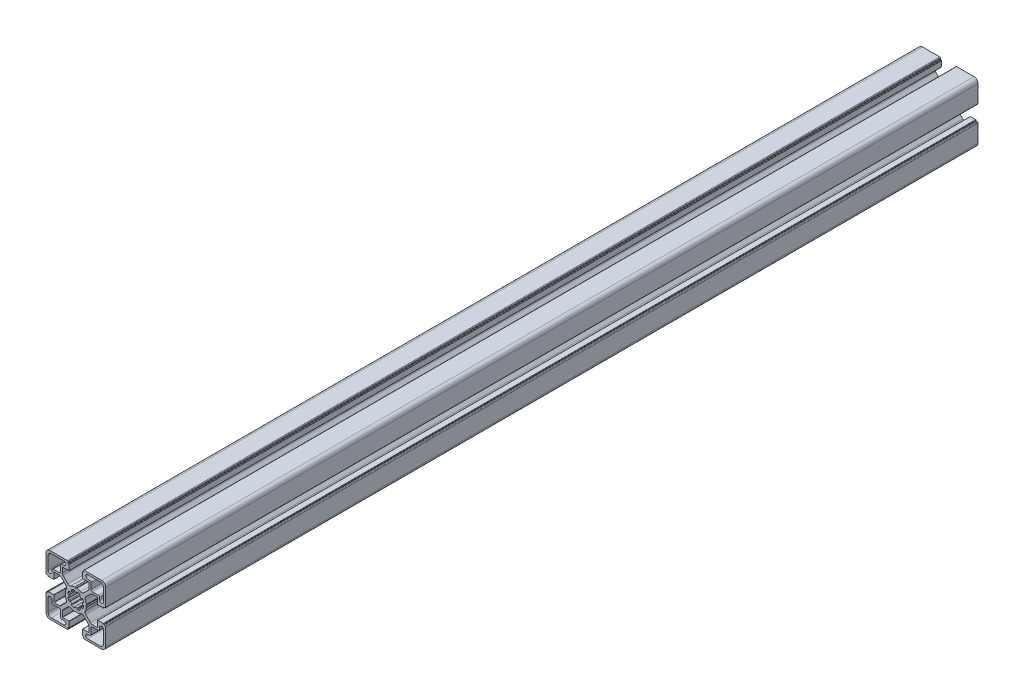
from build123d import *

# Parameters (mm, degrees)
BASE_EXTRUDE_DEPTH = 659


with BuildPart() as part:
    # Sketch1 → Base-Extrude (new body)
    with BuildSketch(Plane.XY):
        with BuildLine():
            Line((7.973976585, 0.792591518), (7.540060475, 0.046829556))
            ThreePointArc((7.540060475, 0.046829556), (7.534295984, 0.023675638), (7.531329941, 0))
            ThreePointArc((7.531329941, 0), (7.534295984, -0.023675638), (7.540060475, -0.046829556))
            Line((7.540060475, -0.046829556), (7.973976585, -0.792591518))
            ThreePointArc((7.973976585, -0.792591518), (7.996666421, -0.851255641), (8.000014047, -0.914065683))
            ThreePointArc((8.000014047, -0.914065683), (7.719730741, -2.298395946), (7.20036345, -3.611859543))
            ThreePointArc((7.20036345, -3.611859543), (7.018857217, -4.793954471), (7.563483933, -5.85869607))
            Line((7.563483933, -5.85869607), (11.129779889, -9.424988026))
            ThreePointArc((11.129779889, -9.424988026), (11.760624613, -9.84650461), (12.504756513, -9.99452154))
            Line((12.504756513, -9.99452154), (16.316902451, -9.99452154))
            ThreePointArc((16.316902451, -9.99452154), (16.458324055, -9.935942793), (16.516902802, -9.794521189))
            Line((16.516902802, -9.794521189), (16.516902802, -5.200014226))
            ThreePointArc((16.516902802, -5.200014226), (16.575481548, -5.058592621), (16.716903152, -5.000013875))
            Line((16.716903152, -5.000013875), (20.719599904, -5.000013875))
            ThreePointArc((20.719599904, -5.000013875), (20.931731427, -5.087881629), (21.01959918, -5.300013151))
            Line((21.01959918, -5.300013151), (21.01959918, -5.500004099))
            ThreePointArc((21.01959918, -5.500004099), (21.10746708, -5.712135974), (21.319598956, -5.800003874))
            Line((21.319598956, -5.800003874), (21.999979514, -5.800003874))
            ThreePointArc((21.999979514, -5.800003874), (22.35353264, -5.946450374), (22.49997914, -6.300003501))
            Line((22.49997914, -6.300003501), (22.49997914, -19.500016116))
            ThreePointArc((22.49997914, -19.500016116), (21.62130014, -21.621334875), (19.499981381, -22.500013875))
            Line((19.499981381, -22.500013875), (6.375709012, -22.500013875))
            ThreePointArc((6.375709012, -22.500013875), (6.022155886, -22.353567375), (5.875709386, -22.000014249))
            Line((5.875709386, -22.000014249), (5.875709386, -21.30001315))
            ThreePointArc((5.875709386, -21.30001315), (5.787841632, -21.087881628), (5.57571011, -21.000013874))
            Line((5.57571011, -21.000013874), (5.299998776, -21.000013874))
            ThreePointArc((5.299998776, -21.000013874), (5.087867607, -20.912146267), (5, -20.700015099))
            Line((5, -20.700015099), (5, -16.666812433))
            ThreePointArc((5, -16.666812433), (5.058578893, -16.525390475), (5.200000851, -16.466811582))
            Line((5.200000851, -16.466811582), (9.905385218, -16.466811582))
            ThreePointArc((9.905385218, -16.466811582), (10.046806822, -16.408232835), (10.105385569, -16.266811231))
            Line((10.105385569, -16.266811231), (10.105385569, -12.471582956))
            ThreePointArc((10.105385569, -12.471582956), (9.953144588, -11.706215861), (9.519598955, -11.057368968))
            Line((9.519598955, -11.057368968), (5.944897989, -7.482668002))
            ThreePointArc((5.944897989, -7.482668002), (4.854601835, -6.967833724), (3.666499237, -7.173289937))
            ThreePointArc((3.666499237, -7.173289937), (2.309136684, -7.713848333), (0.876396038, -8.000013875))
            ThreePointArc((0.876396038, -8.000013875), (0.81356491, -7.997088573), (0.754749577, -7.974793627))
            Line((0.754749577, -7.974793627), (0.11262846, -7.606936933))
            ThreePointArc((0.11262846, -7.606936933), (0.062963903, -7.559088739), (0, -7.530953975))
            ThreePointArc((0, -7.530953975), (-0.062963903, -7.559088739), (-0.11262846, -7.606936933))
            Line((-0.11262846, -7.606936933), (-0.754749577, -7.974793627))
            ThreePointArc((-0.754749577, -7.974793627), (-0.81356491, -7.997088573), (-0.876396038, -8.000013875))
            ThreePointArc((-0.876396038, -8.000013875), (-2.309136684, -7.713848333), (-3.666499237, -7.173289937))
            ThreePointArc((-3.666499237, -7.173289937), (-4.854601835, -6.967833724), (-5.944897989, -7.482668002))
            Line((-5.944897989, -7.482668002), (-9.519598955, -11.057368968))
            ThreePointArc((-9.519598955, -11.057368968), (-9.953144588, -11.706215861), (-10.105385569, -12.471582956))
            Line((-10.105385569, -12.471582956), (-10.105385569, -16.266811231))
            ThreePointArc((-10.105385569, -16.266811231), (-10.046806822, -16.408232835), (-9.905385218, -16.466811582))
            Line((-9.905385218, -16.466811582), (-5.200000851, -16.466811582))
            ThreePointArc((-5.200000851, -16.466811582), (-5.058578893, -16.525390475), (-5, -16.666812433))
            Line((-5, -16.666812433), (-5, -20.700015099))
            ThreePointArc((-5, -20.700015099), (-5.087867607, -20.912146267), (-5.299998776, -21.000013874))
            Line((-5.299998776, -21.000013874), (-5.57571011, -21.000013874))
            ThreePointArc((-5.57571011, -21.000013874), (-5.787841632, -21.087881628), (-5.875709386, -21.30001315))
            Line((-5.875709386, -21.30001315), (-5.875709386, -22.000014249))
            ThreePointArc((-5.875709386, -22.000014249), (-6.022155886, -22.353567375), (-6.375709012, -22.500013875))
            Line((-6.375709012, -22.500013875), (-19.499981381, -22.500013875))
            ThreePointArc((-19.499981381, -22.500013875), (-21.62130014, -21.621334875), (-22.49997914, -19.500016116))
            Line((-22.49997914, -19.500016116), (-22.49997914, -6.300003501))
            ThreePointArc((-22.49997914, -6.300003501), (-22.35353264, -5.946450374), (-21.999979514, -5.800003874))
            Line((-21.999979514, -5.800003874), (-21.319598956, -5.800003874))
            ThreePointArc((-21.319598956, -5.800003874), (-21.10746708, -5.712135974), (-21.01959918, -5.500004099))
            Line((-21.01959918, -5.500004099), (-21.01959918, -5.300013151))
            ThreePointArc((-21.01959918, -5.300013151), (-20.931731427, -5.087881629), (-20.719599904, -5.000013875))
            Line((-20.719599904, -5.000013875), (-16.716903152, -5.000013875))
            ThreePointArc((-16.716903152, -5.000013875), (-16.575481548, -5.058592621), (-16.516902802, -5.200014226))
            Line((-16.516902802, -5.200014226), (-16.516902802, -9.794521189))
            ThreePointArc((-16.516902802, -9.794521189), (-16.458324055, -9.935942793), (-16.316902451, -9.99452154))
            Line((-16.316902451, -9.99452154), (-12.504756513, -9.99452154))
            ThreePointArc((-12.504756513, -9.99452154), (-11.760624613, -9.84650461), (-11.129779889, -9.424988026))
            Line((-11.129779889, -9.424988026), (-7.563483933, -5.85869607))
            ThreePointArc((-7.563483933, -5.85869607), (-7.018857217, -4.793954471), (-7.20036345, -3.611859543))
            ThreePointArc((-7.20036345, -3.611859543), (-7.719730741, -2.298395946), (-8.000014047, -0.914065683))
            ThreePointArc((-8.000014047, -0.914065683), (-7.996666421, -0.851255641), (-7.973976585, -0.792591518))
            Line((-7.973976585, -0.792591518), (-7.540060475, -0.046829556))
            ThreePointArc((-7.540060475, -0.046829556), (-7.534295984, -0.023675638), (-7.531329941, 0))
            ThreePointArc((-7.531329941, 0), (-7.534295984, 0.023675638), (-7.540060475, 0.046829556))
            Line((-7.540060475, 0.046829556), (-7.973976585, 0.792591518))
            ThreePointArc((-7.973976585, 0.792591518), (-7.996666421, 0.851255641), (-8.000014047, 0.914065683))
            ThreePointArc((-8.000014047, 0.914065683), (-7.719730741, 2.298395946), (-7.20036345, 3.611859543))
            ThreePointArc((-7.20036345, 3.611859543), (-7.018857217, 4.793954471), (-7.563483933, 5.85869607))
            Line((-7.563483933, 5.85869607), (-11.129779889, 9.424988026))
            ThreePointArc((-11.129779889, 9.424988026), (-11.760624613, 9.84650461), (-12.504756513, 9.99452154))
            Line((-12.504756513, 9.99452154), (-16.316902451, 9.99452154))
            ThreePointArc((-16.316902451, 9.99452154), (-16.458324055, 9.935942793), (-16.516902802, 9.794521189))
            Line((-16.516902802, 9.794521189), (-16.516902802, 5.200014226))
            ThreePointArc((-16.516902802, 5.200014226), (-16.575481548, 5.058592621), (-16.716903152, 5.000013875))
            Line((-16.716903152, 5.000013875), (-20.719599904, 5.000013875))
            ThreePointArc((-20.719599904, 5.000013875), (-20.931731427, 5.087881629), (-21.01959918, 5.300013151))
            Line((-21.01959918, 5.300013151), (-21.01959918, 5.500004099))
            ThreePointArc((-21.01959918, 5.500004099), (-21.10746708, 5.712135974), (-21.319598956, 5.800003874))
            Line((-21.319598956, 5.800003874), (-21.999979514, 5.800003874))
            ThreePointArc((-21.999979514, 5.800003874), (-22.35353264, 5.946450374), (-22.49997914, 6.300003501))
            Line((-22.49997914, 6.300003501), (-22.49997914, 19.500016116))
            ThreePointArc((-22.49997914, 19.500016116), (-21.62130014, 21.621334875), (-19.499981381, 22.500013875))
            Line((-19.499981381, 22.500013875), (-6.375709012, 22.500013875))
            ThreePointArc((-6.375709012, 22.500013875), (-6.022155886, 22.353567375), (-5.875709386, 22.000014249))
            Line((-5.875709386, 22.000014249), (-5.875709386, 21.30001315))
            ThreePointArc((-5.875709386, 21.30001315), (-5.787841632, 21.087881628), (-5.57571011, 21.000013874))
            Line((-5.57571011, 21.000013874), (-5.299998776, 21.000013874))
            ThreePointArc((-5.299998776, 21.000013874), (-5.087867607, 20.912146267), (-5, 20.700015099))
            Line((-5, 20.700015099), (-5, 16.666812433))
            ThreePointArc((-5, 16.666812433), (-5.058578893, 16.525390475), (-5.200000851, 16.466811582))
            Line((-5.200000851, 16.466811582), (-9.905385218, 16.466811582))
            ThreePointArc((-9.905385218, 16.466811582), (-10.046806822, 16.408232835), (-10.105385569, 16.266811231))
            Line((-10.105385569, 16.266811231), (-10.105385569, 12.471582956))
            ThreePointArc((-10.105385569, 12.471582956), (-9.953144588, 11.706215861), (-9.519598955, 11.057368968))
            Line((-9.519598955, 11.057368968), (-5.944897989, 7.482668002))
            ThreePointArc((-5.944897989, 7.482668002), (-4.854601835, 6.967833724), (-3.666499237, 7.173289937))
            ThreePointArc((-3.666499237, 7.173289937), (-2.309136684, 7.713848333), (-0.876396038, 8.000013875))
            ThreePointArc((-0.876396038, 8.000013875), (-0.81356491, 7.997088573), (-0.754749577, 7.974793627))
            Line((-0.754749577, 7.974793627), (-0.11262846, 7.606936933))
            ThreePointArc((-0.11262846, 7.606936933), (-0.062963903, 7.559088739), (0, 7.530953975))
            ThreePointArc((0, 7.530953975), (0.062963903, 7.559088739), (0.11262846, 7.606936933))
            Line((0.11262846, 7.606936933), (0.754749577, 7.974793627))
            ThreePointArc((0.754749577, 7.974793627), (0.81356491, 7.997088573), (0.876396038, 8.000013875))
            ThreePointArc((0.876396038, 8.000013875), (2.309136684, 7.713848333), (3.666499237, 7.173289937))
            ThreePointArc((3.666499237, 7.173289937), (4.854601835, 6.967833724), (5.944897989, 7.482668002))
            Line((5.944897989, 7.482668002), (9.519598955, 11.057368968))
            ThreePointArc((9.519598955, 11.057368968), (9.953144588, 11.706215861), (10.105385569, 12.471582956))
            Line((10.105385569, 12.471582956), (10.105385569, 16.266811231))
            ThreePointArc((10.105385569, 16.266811231), (10.046806822, 16.408232835), (9.905385218, 16.466811582))
            Line((9.905385218, 16.466811582), (5.200000851, 16.466811582))
            ThreePointArc((5.200000851, 16.466811582), (5.058578893, 16.525390475), (5, 16.666812433))
            Line((5, 16.666812433), (5, 20.700015099))
            ThreePointArc((5, 20.700015099), (5.087867607, 20.912146267), (5.299998776, 21.000013874))
            Line((5.299998776, 21.000013874), (5.57571011, 21.000013874))
            ThreePointArc((5.57571011, 21.000013874), (5.787841632, 21.087881628), (5.875709386, 21.30001315))
            Line((5.875709386, 21.30001315), (5.875709386, 22.000014249))
            ThreePointArc((5.875709386, 22.000014249), (6.022155886, 22.353567375), (6.375709012, 22.500013875))
            Line((6.375709012, 22.500013875), (19.499981381, 22.500013875))
            ThreePointArc((19.499981381, 22.500013875), (21.62130014, 21.621334875), (22.49997914, 19.500016116))
            Line((22.49997914, 19.500016116), (22.49997914, 6.300003501))
            ThreePointArc((22.49997914, 6.300003501), (22.35353264, 5.946450374), (21.999979514, 5.800003874))
            Line((21.999979514, 5.800003874), (21.319598956, 5.800003874))
            ThreePointArc((21.319598956, 5.800003874), (21.10746708, 5.712135974), (21.01959918, 5.500004099))
            Line((21.01959918, 5.500004099), (21.01959918, 5.300013151))
            ThreePointArc((21.01959918, 5.300013151), (20.931731427, 5.087881629), (20.719599904, 5.000013875))
            Line((20.719599904, 5.000013875), (16.716903152, 5.000013875))
            ThreePointArc((16.716903152, 5.000013875), (16.575481548, 5.058592621), (16.516902802, 5.200014226))
            Line((16.516902802, 5.200014226), (16.516902802, 9.794521189))
            ThreePointArc((16.516902802, 9.794521189), (16.458324055, 9.935942793), (16.316902451, 9.99452154))
            Line((16.316902451, 9.99452154), (12.504756513, 9.99452154))
            ThreePointArc((12.504756513, 9.99452154), (11.760624613, 9.84650461), (11.129779889, 9.424988026))
            Line((11.129779889, 9.424988026), (7.563483933, 5.85869607))
            ThreePointArc((7.563483933, 5.85869607), (7.018857217, 4.793954471), (7.20036345, 3.611859543))
            ThreePointArc((7.20036345, 3.611859543), (7.719730741, 2.298395946), (8.000014047, 0.914065683))
            ThreePointArc((8.000014047, 0.914065683), (7.996666421, 0.851255641), (7.973976585, 0.792591518))
        make_face()
        with BuildLine():
            Line((10.549978885, 18.000013874), (8.999979138, 18.000013874))
            ThreePointArc((8.999979138, 18.000013874), (7.499979138, 19.500013874), (8.999979138, 21.000013874))
            Line((8.999979138, 21.000013874), (18.499981006, 21.000013874))
            ThreePointArc((18.499981006, 21.000013874), (20.267746638, 20.267781374), (20.999979138, 18.500015742))
            Line((20.999979138, 18.500015742), (20.999979138, 9.000204874))
            ThreePointArc((20.999979138, 9.000204874), (19.499979138, 7.500204874), (17.999979138, 9.000204874))
            Line((17.999979138, 9.000204874), (17.999979138, 10.550013621))
            ThreePointArc((17.999979138, 10.550013621), (17.707086138, 11.257119874), (16.999979885, 11.550012874))
            Line((16.999979885, 11.550012874), (12.549977391, 11.550012874))
            ThreePointArc((12.549977391, 11.550012874), (11.842871138, 11.842905874), (11.549978138, 12.550012127))
            Line((11.549978138, 12.550012127), (11.549978138, 17.000014621))
            ThreePointArc((11.549978138, 17.000014621), (11.257085138, 17.707120874), (10.549978885, 18.000013874))
        make_face(mode=Mode.SUBTRACT)
        with BuildLine():
            Line((-0.867388737, 4.924188946), (-0.96752168, 5.481112935))
            ThreePointArc((-0.96752168, 5.481112935), (-1.187855719, 5.829589164), (-1.595071417, 5.894072848))
            ThreePointArc((-1.595071417, 5.894072848), (-2.338895973, 5.643477696), (-3.04438497, 5.299445466))
            ThreePointArc((-3.04438497, 5.299445466), (-3.284615367, 4.964275075), (-3.191311906, 4.562598216))
            Line((-3.191311906, 4.562598216), (-2.864000421, 4.09847552))
            ThreePointArc((-2.864000421, 4.09847552), (-3.53013295, 3.540926624), (-4.08971289, 2.876499344))
            Line((-4.08971289, 2.876499344), (-4.566777651, 3.208162503))
            ThreePointArc((-4.566777651, 3.208162503), (-4.968960845, 3.298770682), (-5.302497889, 3.056460542))
            ThreePointArc((-5.302497889, 3.056460542), (-5.651259984, 2.353310881), (-5.906847665, 1.611199444))
            ThreePointArc((-5.906847665, 1.611199444), (-5.839752063, 1.204293023), (-5.489730697, 0.98621116))
            Line((-5.489730697, 0.98621116), (-4.920545766, 0.887822825))
            ThreePointArc((-4.920545766, 0.887822825), (-4.980096828, 0.445685524), (-5, 0))
            ThreePointArc((-5, 0), (-4.980096828, -0.445685524), (-4.920545766, -0.887822825))
            Line((-4.920545766, -0.887822825), (-5.489730697, -0.98621116))
            ThreePointArc((-5.489730697, -0.98621116), (-5.839752063, -1.204293023), (-5.906847665, -1.611199444))
            ThreePointArc((-5.906847665, -1.611199444), (-5.651259984, -2.353310881), (-5.302497889, -3.056460542))
            ThreePointArc((-5.302497889, -3.056460542), (-4.968960845, -3.298770682), (-4.566777651, -3.208162503))
            Line((-4.566777651, -3.208162503), (-4.08971289, -2.876499344))
            ThreePointArc((-4.08971289, -2.876499344), (-3.53013295, -3.540926624), (-2.864000421, -4.09847552))
            Line((-2.864000421, -4.09847552), (-3.191311906, -4.562598216))
            ThreePointArc((-3.191311906, -4.562598216), (-3.284615367, -4.964275075), (-3.04438497, -5.299445466))
            ThreePointArc((-3.04438497, -5.299445466), (-2.338895973, -5.643477696), (-1.595071417, -5.894072848))
            ThreePointArc((-1.595071417, -5.894072848), (-1.187855719, -5.829589164), (-0.96752168, -5.481112935))
            Line((-0.96752168, -5.481112935), (-0.867388737, -4.924188946))
            ThreePointArc((-0.867388737, -4.924188946), (0, -5), (0.867388737, -4.924188946))
            Line((0.867388737, -4.924188946), (0.96752168, -5.481112935))
            ThreePointArc((0.96752168, -5.481112935), (1.187855719, -5.829589164), (1.595071417, -5.894072848))
            ThreePointArc((1.595071417, -5.894072848), (2.338895973, -5.643477696), (3.04438497, -5.299445466))
            ThreePointArc((3.04438497, -5.299445466), (3.284615367, -4.964275075), (3.191311906, -4.562598216))
            Line((3.191311906, -4.562598216), (2.864000421, -4.09847552))
            ThreePointArc((2.864000421, -4.09847552), (3.53013295, -3.540926624), (4.08971289, -2.876499344))
            Line((4.08971289, -2.876499344), (4.566777651, -3.208162503))
            ThreePointArc((4.566777651, -3.208162503), (4.968960845, -3.298770682), (5.302497889, -3.056460542))
            ThreePointArc((5.302497889, -3.056460542), (5.651259984, -2.353310881), (5.906847665, -1.611199444))
            ThreePointArc((5.906847665, -1.611199444), (5.839752063, -1.204293023), (5.489730697, -0.98621116))
            Line((5.489730697, -0.98621116), (4.920545766, -0.887822825))
            ThreePointArc((4.920545766, -0.887822825), (4.980096828, -0.445685524), (5, 0))
            ThreePointArc((5, 0), (4.980096828, 0.445685524), (4.920545766, 0.887822825))
            Line((4.920545766, 0.887822825), (5.489730697, 0.98621116))
            ThreePointArc((5.489730697, 0.98621116), (5.839752063, 1.204293023), (5.906847665, 1.611199444))
            ThreePointArc((5.906847665, 1.611199444), (5.651259984, 2.353310881), (5.302497889, 3.056460542))
            ThreePointArc((5.302497889, 3.056460542), (4.968960845, 3.298770682), (4.566777651, 3.208162503))
            Line((4.566777651, 3.208162503), (4.08971289, 2.876499344))
            ThreePointArc((4.08971289, 2.876499344), (3.53013295, 3.540926624), (2.864000421, 4.09847552))
            Line((2.864000421, 4.09847552), (3.191311906, 4.562598216))
            ThreePointArc((3.191311906, 4.562598216), (3.284615367, 4.964275075), (3.04438497, 5.299445466))
            ThreePointArc((3.04438497, 5.299445466), (2.338895973, 5.643477696), (1.595071417, 5.894072848))
            ThreePointArc((1.595071417, 5.894072848), (1.187855719, 5.829589164), (0.96752168, 5.481112935))
            Line((0.96752168, 5.481112935), (0.867388737, 4.924188946))
            ThreePointArc((0.867388737, 4.924188946), (0, 5), (-0.867388737, 4.924188946))
        make_face(mode=Mode.SUBTRACT)
        with BuildLine():
            Line((-10.549978885, -18.000013874), (-8.999979138, -18.000013874))
            ThreePointArc((-8.999979138, -18.000013874), (-7.499979138, -19.500013874), (-8.999979138, -21.000013874))
            Line((-8.999979138, -21.000013874), (-18.499981006, -21.000013874))
            ThreePointArc((-18.499981006, -21.000013874), (-20.267746638, -20.267781374), (-20.999979138, -18.500015742))
            Line((-20.999979138, -18.500015742), (-20.999979138, -9.000204874))
            ThreePointArc((-20.999979138, -9.000204874), (-19.499979138, -7.500204874), (-17.999979138, -9.000204874))
            Line((-17.999979138, -9.000204874), (-17.999979138, -10.550013621))
            ThreePointArc((-17.999979138, -10.550013621), (-17.707086138, -11.257119874), (-16.999979885, -11.550012874))
            Line((-16.999979885, -11.550012874), (-12.549977391, -11.550012874))
            ThreePointArc((-12.549977391, -11.550012874), (-11.842871138, -11.842905874), (-11.549978138, -12.550012127))
            Line((-11.549978138, -12.550012127), (-11.549978138, -17.000014621))
            ThreePointArc((-11.549978138, -17.000014621), (-11.257085138, -17.707120874), (-10.549978885, -18.000013874))
        make_face(mode=Mode.SUBTRACT)
        with BuildLine():
            Line((-11.549978138, 12.550012127), (-11.549978138, 17.000014621))
            ThreePointArc((-11.549978138, 17.000014621), (-11.257085138, 17.707120874), (-10.549978885, 18.000013874))
            Line((-10.549978885, 18.000013874), (-8.999979138, 18.000013874))
            ThreePointArc((-8.999979138, 18.000013874), (-7.499979138, 19.500013874), (-8.999979138, 21.000013874))
            Line((-8.999979138, 21.000013874), (-18.499981006, 21.000013874))
            ThreePointArc((-18.499981006, 21.000013874), (-20.267746638, 20.267781374), (-20.999979138, 18.500015742))
            Line((-20.999979138, 18.500015742), (-20.999979138, 9.000204874))
            ThreePointArc((-20.999979138, 9.000204874), (-19.499979138, 7.500204874), (-17.999979138, 9.000204874))
            Line((-17.999979138, 9.000204874), (-17.999979138, 10.550013621))
            ThreePointArc((-17.999979138, 10.550013621), (-17.707086138, 11.257119874), (-16.999979885, 11.550012874))
            Line((-16.999979885, 11.550012874), (-12.549977391, 11.550012874))
            ThreePointArc((-12.549977391, 11.550012874), (-11.842871138, 11.842905874), (-11.549978138, 12.550012127))
        make_face(mode=Mode.SUBTRACT)
        with BuildLine():
            Line((11.549978138, -12.550012127), (11.549978138, -17.000014621))
            ThreePointArc((11.549978138, -17.000014621), (11.257085138, -17.707120874), (10.549978885, -18.000013874))
            Line((10.549978885, -18.000013874), (8.999979138, -18.000013874))
            ThreePointArc((8.999979138, -18.000013874), (7.499979138, -19.500013874), (8.999979138, -21.000013874))
            Line((8.999979138, -21.000013874), (18.499981006, -21.000013874))
            ThreePointArc((18.499981006, -21.000013874), (20.267746638, -20.267781374), (20.999979138, -18.500015742))
            Line((20.999979138, -18.500015742), (20.999979138, -9.000204874))
            ThreePointArc((20.999979138, -9.000204874), (19.499979138, -7.500204874), (17.999979138, -9.000204874))
            Line((17.999979138, -9.000204874), (17.999979138, -10.550013621))
            ThreePointArc((17.999979138, -10.550013621), (17.707086138, -11.257119874), (16.999979885, -11.550012874))
            Line((16.999979885, -11.550012874), (12.549977391, -11.550012874))
            ThreePointArc((12.549977391, -11.550012874), (11.842871138, -11.842905874), (11.549978138, -12.550012127))
        make_face(mode=Mode.SUBTRACT)
    extrude(amount=-BASE_EXTRUDE_DEPTH)


solid = part.part
